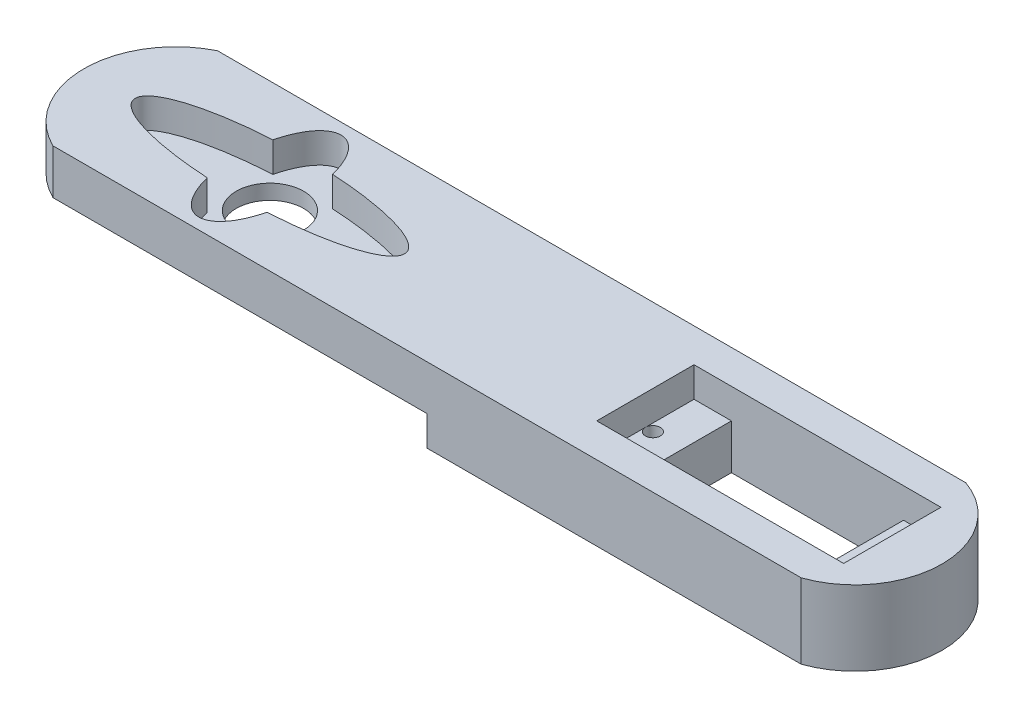
from build123d import *

# Parameters (mm, degrees)
EXTRUDE_1_DEPTH     = 10
SKETCH_2_R          = 4.5
CUT_EXTRUDE_1_DEPTH = 21
CUT_EXTRUDE_2_DEPTH = 4
SKETCH_4_W          = 23
SKETCH_4_H          = 13
CUT_EXTRUDE_3_DEPTH = 21
SKETCH_5_W          = 5
SKETCH_5_H          = 13
CUT_EXTRUDE_4_DEPTH = 4
CUT_EXTRUDE_5_DEPTH = 10
SKETCH_7_R          = 1
CUT_EXTRUDE_6_DEPTH = 11
CUT_EXTRUDE_7_DEPTH = 4


with BuildPart() as part:
    # 草图1 → 凸台-拉伸1 (new body, symmetric)
    with BuildSketch(Plane(origin=(0, 0, 0), x_dir=(1, 0, 0), z_dir=(0, 1, 0))):
        with BuildLine():
            Line((-18, 11), (82, 11))
            ThreePointArc((82, 11), (89.822046697, 0), (82, -11))
            Line((82, -11), (-18, -11))
            ThreePointArc((-18, -11), (-24.855224852, 0), (-18, 11))
        make_face()
    extrude(amount=EXTRUDE_1_DEPTH, both=True)

    # 草图2 → 切除-拉伸1 (cut, through all)
    with BuildSketch(Plane(origin=(0, 10, 0), x_dir=(1, 0, 0), z_dir=(0, 1, 0))):
        Circle(SKETCH_2_R)
    extrude(amount=-CUT_EXTRUDE_1_DEPTH, mode=Mode.SUBTRACT)

    # 草图3 → 切除-拉伸2 (cut)
    with BuildSketch(Plane(origin=(0, 10, 0), x_dir=(1, 0, 0), z_dir=(0, 1, 0))):
        with BuildLine():
            add(Edge.make_bspline(
                [(-3.991210712, 4.387982431), (-18, 3.591602336), (-18, 0), (-18, -3.591602336), (-3.991210712, -4.387982431)],
                knots=[1.794388632, 1.794388632, 1.794388632, 3.141592654, 3.141592654, 4.488796676, 4.488796676, 4.488796676], degree=2, weights=[1, 0.781579788, 1, 0.781579788, 1]))
            add(Edge.make_bspline(
                [(-3.991210712, -4.387982431), (0, -20.567539049), (3.991210712, -4.387982431)],
                knots=[2.05092453, 2.05092453, 2.05092453, 4.232260777, 4.232260777, 4.232260777], degree=2, weights=[1, 0.461892887, 1]))
            add(Edge.make_bspline(
                [(3.991210712, -4.387982431), (18, -3.591602336), (18, 0), (18, 3.591602336), (3.991210712, 4.387982431)],
                knots=[4.935981285, 4.935981285, 4.935981285, 6.283185307, 6.283185307, 7.630389329, 7.630389329, 7.630389329], degree=2, weights=[1, 0.781579788, 1, 0.781579788, 1]))
            add(Edge.make_bspline(
                [(3.991210712, 4.387982431), (0, 20.567539049), (-3.991210712, 4.387982431)],
                knots=[5.192517184, 5.192517184, 5.192517184, 7.373853431, 7.373853431, 7.373853431], degree=2, weights=[1, 0.461892887, 1]))
        make_face()
    extrude(amount=-CUT_EXTRUDE_2_DEPTH, mode=Mode.SUBTRACT)

    # 草图4 → 切除-拉伸3 (cut, through all)
    with BuildSketch(Plane(origin=(0, 10, 0), x_dir=(1, 0, 0), z_dir=(0, 1, 0))):
        with Locations((66.67647479, 0)):
            Rectangle(SKETCH_4_W, SKETCH_4_H)
    extrude(amount=-CUT_EXTRUDE_3_DEPTH, mode=Mode.SUBTRACT)

    # 草图5 → 切除-拉伸4 (cut)
    with BuildSketch(Plane(origin=(0, 10, 0), x_dir=(1, 0, 0), z_dir=(0, 1, 0))):
        with Locations((52.67647479, 0)):
            Rectangle(SKETCH_5_W, SKETCH_5_H)
        with Locations((80.67647479, 0)):
            Rectangle(SKETCH_5_W, SKETCH_5_H)
    extrude(amount=-CUT_EXTRUDE_4_DEPTH, mode=Mode.SUBTRACT)

    # 草图6 → 切除-拉伸5 (cut)
    with BuildSketch(Plane(origin=(0, -10, 0), x_dir=(-1, 0, 0), z_dir=(0, -1, 0))):
        with BuildLine():
            Line((18, 11), (-82, 11))
            ThreePointArc((-82, 11), (-89.822046697, 0), (-82, -11))
            Line((-82, -11), (18, -11))
            ThreePointArc((18, -11), (24.855224852, 0), (18, 11))
        make_face()
    extrude(amount=-CUT_EXTRUDE_5_DEPTH, mode=Mode.SUBTRACT)

    # 草图7 → 切除-拉伸6 (cut, through all)
    with BuildSketch(Plane(origin=(0, 10, 0), x_dir=(1, 0, 0), z_dir=(0, 1, 0))):
        with Locations((82.17647479, 0)):
            Circle(SKETCH_7_R)
        with Locations((51.17647479, 0)):
            Circle(SKETCH_7_R)
    extrude(amount=-CUT_EXTRUDE_6_DEPTH, mode=Mode.SUBTRACT)

    # 草图8 → 切除-拉伸7 (cut)
    with BuildSketch(Plane(origin=(0, 0, 0), x_dir=(-1, 0, 0), z_dir=(0, -1, 0))):
        with BuildLine():
            Line((-32, -11), (18, -11))
            ThreePointArc((18, -11), (24.855224852, 0), (18, 11))
            Line((18, 11), (-32, 11))
            Line((-32, 11), (-32, -11))
        make_face()
    extrude(amount=-CUT_EXTRUDE_7_DEPTH, mode=Mode.SUBTRACT)


solid = part.part
